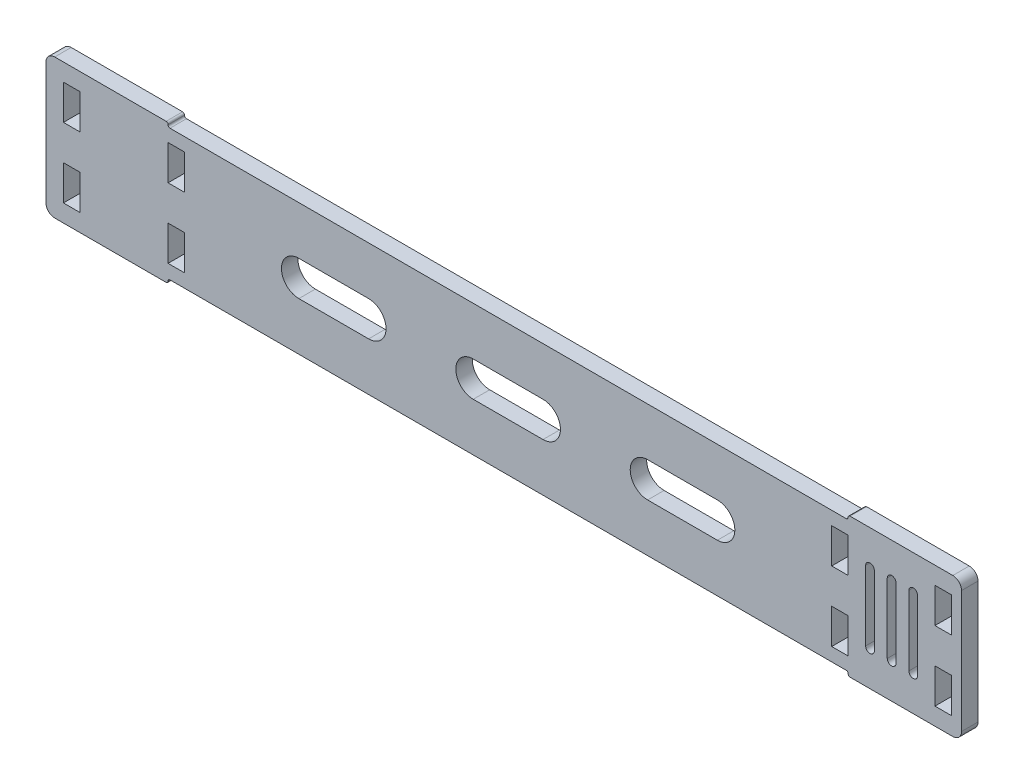
from build123d import *

# Parameters (mm, degrees)
SKETCH1_W           = 304.8
SKETCH1_H           = 50.8
SKETCH1_W_2         = 5.9944
SKETCH1_H_2         = 12.7
BOSS_EXTRUDE1_DEPTH = 5.9944
SKETCH3_W           = 247.65
SKETCH3_H           = 1.4875
CUT_EXTRUDE3_DEPTH  = 6.9944
FILLET4_R           = 0.7
SKETCH4_W           = 28.575
SKETCH4_H           = 50.8
BOSS_EXTRUDE2_DEPTH = 5.9944
SKETCH5_W           = 5.9944
SKETCH5_H           = 12.7
CUT_EXTRUDE4_DEPTH  = 6.9944
FILLET5_R           = 3.175
CUT_EXTRUDE5_DEPTH  = 6.9944
CUT_EXTRUDE6_DEPTH  = 6.9944


with BuildPart() as part:
    # Sketch1 → Boss-Extrude1 (new body)
    with BuildSketch(Plane.XY):
        with Locations((-152.4, 25.4)):
            Rectangle(SKETCH1_W, SKETCH1_H)
        with Locations((-15.6972, 12.7)):
            Rectangle(SKETCH1_W_2, SKETCH1_H_2, mode=Mode.SUBTRACT)
        with Locations((-15.6972, 38.1)):
            Rectangle(SKETCH1_W_2, SKETCH1_H_2, mode=Mode.SUBTRACT)
        with Locations((-257.3528, 38.1)):
            Rectangle(SKETCH1_W_2, SKETCH1_H_2, mode=Mode.SUBTRACT)
        with Locations((-257.3528, 12.7)):
            Rectangle(SKETCH1_W_2, SKETCH1_H_2, mode=Mode.SUBTRACT)
        with Locations((-295.4528, 12.7)):
            Rectangle(SKETCH1_W_2, SKETCH1_H_2, mode=Mode.SUBTRACT)
        with Locations((-295.4528, 38.1)):
            Rectangle(SKETCH1_W_2, SKETCH1_H_2, mode=Mode.SUBTRACT)
    extrude(amount=BOSS_EXTRUDE1_DEPTH)

    # Sketch3 → Cut-Extrude3 (cut, through all)
    with BuildSketch(Plane.XY.offset(5.9944)):
        with Locations((-136.525, 50.05625)):
            Rectangle(SKETCH3_W, SKETCH3_H)
        with Locations((-136.525, 0.74375)):
            Rectangle(SKETCH3_W, SKETCH3_H)
    extrude(amount=-CUT_EXTRUDE3_DEPTH, mode=Mode.SUBTRACT)

    # Fillet4
    fillet4_edges = [part.edges().sort_by_distance(p)[0] for p in [
        (-260.35, 49.3125, 2.9972),
        (-260.35, 50.8, 2.9972),
        (-12.7, 50.8, 2.9972),
        (-12.7, 49.3125, 2.9972),
        (-12.7, 0, 2.9972),
        (-260.35, 0, 2.9972),
        (-260.35, 1.4875, 2.9972),
        (-12.7, 1.4875, 2.9972),
    ]]
    fillet(fillet4_edges, radius=FILLET4_R)

    # Sketch4 → Boss-Extrude2 (add)
    with BuildSketch(Plane.XY.offset(5.9944)):
        with Locations((14.2875, 25.4)):
            Rectangle(SKETCH4_W, SKETCH4_H)
    extrude(amount=-BOSS_EXTRUDE2_DEPTH)

    # Sketch5 → Cut-Extrude4 (cut, through all)
    with BuildSketch(Plane.XY.offset(5.9944)):
        with Locations((21.893276, 38.1)):
            Rectangle(SKETCH5_W, SKETCH5_H)
        with Locations((21.893276, 12.7)):
            Rectangle(SKETCH5_W, SKETCH5_H)
    extrude(amount=-CUT_EXTRUDE4_DEPTH, mode=Mode.SUBTRACT)

    # Fillet5
    fillet5_edges = [part.edges().sort_by_distance(p)[0] for p in [
        (28.575, 50.8, 2.9972),
        (28.575, 0, 2.9972),
        (-304.8, 0, 2.9972),
        (-304.8, 50.8, 2.9972),
    ]]
    fillet(fillet5_edges, radius=FILLET5_R)

    # Sketch6 → Cut-Extrude5 (cut, through all)
    with BuildSketch(Plane.XY.offset(5.9944)):
        with BuildLine():
            Line((-123.825, 19.05), (-149.225, 19.05))
            ThreePointArc((-149.225, 19.05), (-155.575, 25.4), (-149.225, 31.75))
            Line((-149.225, 31.75), (-123.825, 31.75))
            ThreePointArc((-123.825, 31.75), (-117.475, 25.4), (-123.825, 19.05))
        make_face()
        with BuildLine():
            Line((-60.325, 19.05), (-85.725, 19.05))
            ThreePointArc((-85.725, 19.05), (-92.075, 25.4), (-85.725, 31.75))
            Line((-85.725, 31.75), (-60.325, 31.75))
            ThreePointArc((-60.325, 31.75), (-53.975, 25.4), (-60.325, 19.05))
        make_face()
        with BuildLine():
            Line((-187.325, 19.05), (-212.725, 19.05))
            ThreePointArc((-212.725, 19.05), (-219.075, 25.4), (-212.725, 31.75))
            Line((-212.725, 31.75), (-187.325, 31.75))
            ThreePointArc((-187.325, 31.75), (-180.975, 25.4), (-187.325, 19.05))
        make_face()
    extrude(amount=-CUT_EXTRUDE5_DEPTH, mode=Mode.SUBTRACT)

    # Sketch7 → Cut-Extrude6 (cut, through all)
    with BuildSketch(Plane.XY.offset(5.9944)):
        with BuildLine():
            Line((-6.35, 12.7), (-6.35, 38.1))
            ThreePointArc((-6.35, 38.1), (-4.7625, 39.6875), (-3.175, 38.1))
            Line((-3.175, 38.1), (-3.175, 12.7))
            ThreePointArc((-3.175, 12.7), (-4.7625, 11.1125), (-6.35, 12.7))
        make_face()
        with BuildLine():
            Line((1.524, 12.7), (1.524, 38.1))
            ThreePointArc((1.524, 38.1), (3.1115, 39.6875), (4.699, 38.1))
            Line((4.699, 38.1), (4.699, 12.7))
            ThreePointArc((4.699, 12.7), (3.1115, 11.1125), (1.524, 12.7))
        make_face()
        with BuildLine():
            Line((9.398, 12.7), (9.398, 38.1))
            ThreePointArc((9.398, 38.1), (10.9855, 39.6875), (12.573, 38.1))
            Line((12.573, 38.1), (12.573, 12.7))
            ThreePointArc((12.573, 12.7), (10.9855, 11.1125), (9.398, 12.7))
        make_face()
    extrude(amount=-CUT_EXTRUDE6_DEPTH, mode=Mode.SUBTRACT)


solid = part.part
